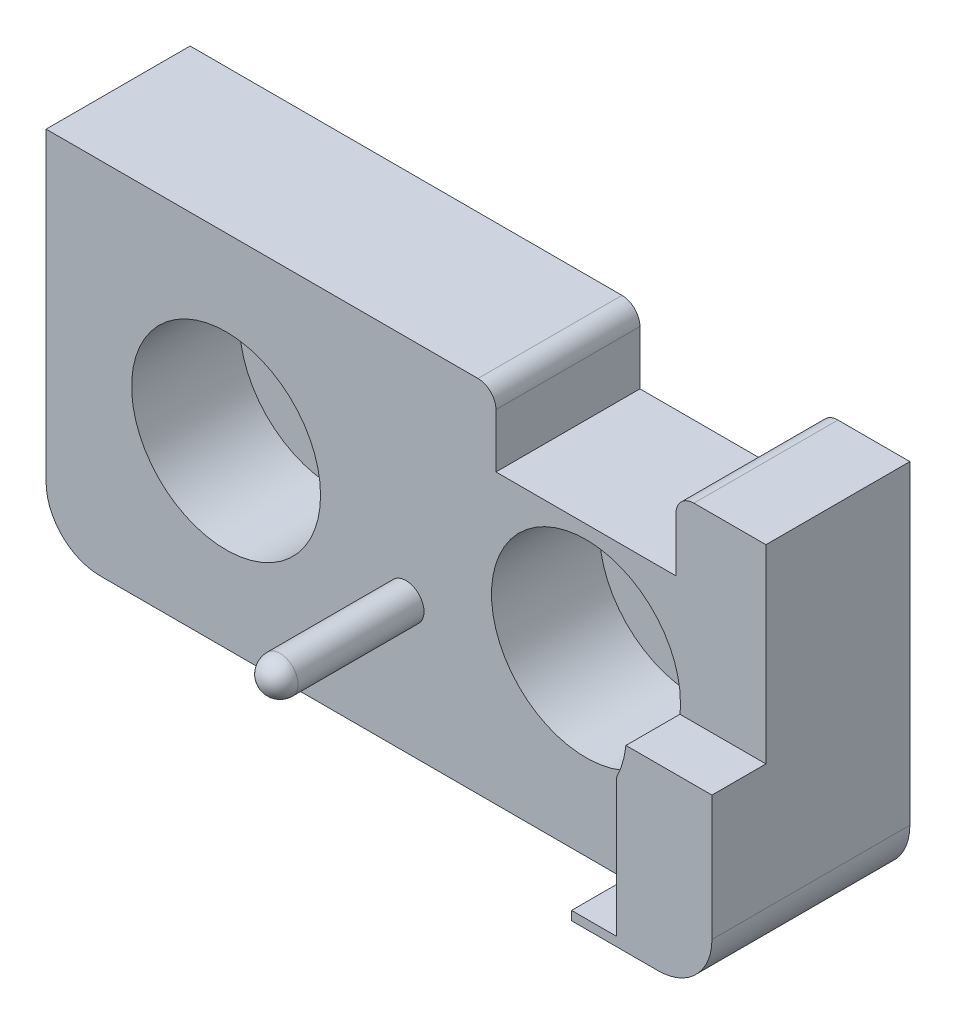
from build123d import *

# Parameters (mm, degrees)
BOSS_EXTRUDE1_DEPTH            = 8
CBORE_FOR_M5_SHCS1_D           = 5.5
CBORE_FOR_M5_SHCS1_DEPTH       = 8
CBORE_FOR_M5_SHCS1_CBORE_D     = 10.5
CBORE_FOR_M5_SHCS1_CBORE_DEPTH = 6
SKETCH6_R                      = 1
BOSS_EXTRUDE3_DEPTH            = 8
FILLET2_R                      = 1
BOSS_EXTRUDE4_DEPTH            = 3
BOSS_EXTRUDE4_DEPTH_BACK       = 8


with BuildPart() as part:
    # Sketch1 → Boss-Extrude1 (new body)
    with BuildSketch(Plane.XY):
        with BuildLine():
            Line((-17, -10), (17, -10))
            ThreePointArc((17, -10), (19.121320344, -9.121320344), (20, -7))
            Line((20, -7), (20, 10))
            Line((20, 10), (16, 10))
            ThreePointArc((16, 10), (15.292893219, 9.707106781), (15, 9))
            Line((15, 9), (15, 6))
            Line((15, 6), (5, 6))
            Line((5, 6), (5, 9))
            ThreePointArc((5, 9), (4.707106781, 9.707106781), (4, 10))
            Line((4, 10), (-20, 10))
            Line((-20, 10), (-20, -7))
            ThreePointArc((-20, -7), (-19.121320344, -9.121320344), (-17, -10))
        make_face()
    extrude(amount=BOSS_EXTRUDE1_DEPTH)

    # CBORE for M5 SHCS1
    with Locations(Plane.XY.offset(8)):
        with Locations((-10, 0), (10, 0)):
            CounterBoreHole(CBORE_FOR_M5_SHCS1_D / 2, CBORE_FOR_M5_SHCS1_CBORE_D / 2, CBORE_FOR_M5_SHCS1_CBORE_DEPTH, depth=CBORE_FOR_M5_SHCS1_DEPTH)

    # Sketch6 → Boss-Extrude3 (add)
    with BuildSketch(Plane.XY.offset(8)):
        with Locations((0, -2.727298247)):
            Circle(SKETCH6_R)
    extrude(amount=BOSS_EXTRUDE3_DEPTH)

    # Fillet2
    fillet2_edges = [part.edges().sort_by_distance(p)[0] for p in [
        (-1, -2.727298247, 16),
    ]]
    fillet(fillet2_edges, radius=FILLET2_R)

    # Sketch7 → Boss-Extrude4 (add, two sides)
    with BuildSketch(Plane.XY.offset(8)) as boss_extrude4_sk:
        with BuildLine():
            Line((20, -0.55), (15.221110993, -0.55))
            ThreePointArc((15.221110993, -0.55), (15.040589551, -1.467977174), (14.7, -2.339337513))
            Line((14.7, -2.339337513), (14.7, -10))
            Line((14.7, -10), (12.2, -10))
            Line((12.2, -10), (12.2, -10.5))
            Line((12.2, -10.5), (17, -10.5))
            ThreePointArc((17, -10.5), (19.121320344, -9.621320344), (20, -7.5))
            Line((20, -7.5), (20, -0.55))
        make_face()
    extrude(amount=BOSS_EXTRUDE4_DEPTH)
    extrude(boss_extrude4_sk.sketch, amount=-BOSS_EXTRUDE4_DEPTH_BACK)


solid = part.part
